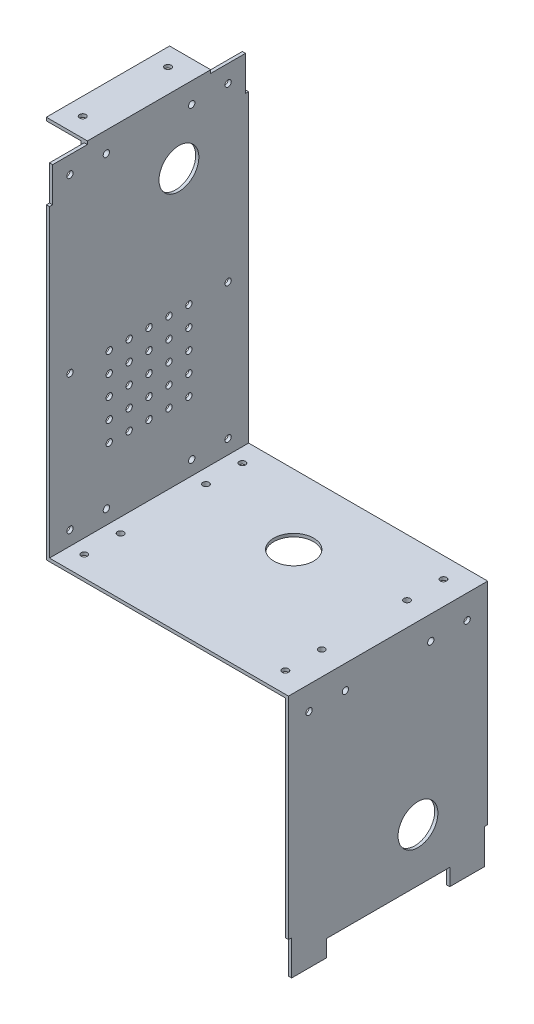
from build123d import *

# Parameters (mm, degrees)
BOSS_EXTRU_1_DEPTH       = 100
ESQUISSE2_W              = 19.05
ESQUISSE2_H              = 61.9
BOSS_EXTRU_2_DEPTH       = 1.5875
ESQUISSE3_W              = 1.5875
ESQUISSE3_H              = 61.9
BOSS_EXTRU_3_DEPTH       = 17.4625
ESQUISSE4_W              = 61.9
ESQUISSE4_H              = 19.05
BOSS_EXTRU_4_DEPTH       = 1.5875
ESQUISSE5_W              = 61.9
ESQUISSE5_H              = 1.5875
BOSS_EXTRU_5_DEPTH       = 17.4625
ESQUISSE7_W              = 61.9
ESQUISSE7_H              = 19.05
BOSS_EXTRU_6_DEPTH       = 1.5875
ESQUISSE8_W              = 61.9
ESQUISSE8_H              = 1.5875
BOSS_EXTRU_7_DEPTH       = 17.4625
ENL_V_MAT_EXTRU_1_REACH  = 125.175
ESQUISSE11_R             = 1.5875
ENL_V_MAT_EXTRU_2_REACH  = 177.005
ESQUISSE12_R             = 1.5875
ENL_V_MAT_EXTRU_3_REACH  = 5.175
ESQUISSE13_R             = 1.5875
ENL_V_MAT_EXTRU_4_REACH  = 3.588
ESQUISSE14_R             = 1.5875
ENL_V_MAT_EXTRU_6_REACH  = 123.588
ESQUISSE16_R             = 10
ENL_V_MAT_EXTRU_7_REACH  = 175.418
ESQUISSE17_R             = 10
ENL_V_MAT_EXTRU_8_REACH  = 123.588
ESQUISSE18_R             = 1.5875
ENL_V_MAT_EXTRU_9_REACH  = 3.588
ESQUISSE19_R             = 1.5875
ENL_V_MAT_EXTRU_10_REACH = 175.418
ESQUISSE20_R             = 1.5875
ESQUISSE21_R             = 1.5875
ENL_V_MAT_EXTRU_11_DEPTH = 1.5875
ENL_V_MAT_EXTRU_12_REACH = 3.588
ESQUISSE22_R             = 10


with BuildPart() as part:
    # Esquisse1 → Boss.-Extru.1 (new body)
    with BuildSketch(Plane.XY):
        Polygon((-113.850503037, 166.83494186), (-113.850503037, -6.58255814), (6.149496963, -6.58255814), (6.149496963, -129.94130814), (7.736996963, -129.94130814), (7.736996963, -4.99505814), (-112.263003037, -4.99505814), (-112.263003037, 166.83494186), align=None)
    extrude(amount=BOSS_EXTRU_1_DEPTH)

    # Esquisse2 → Boss.-Extru.2 (add)
    with BuildSketch(Plane.XZ.offset(6.58255814)):
        with Locations((-105.913003037, 50)):
            Rectangle(ESQUISSE2_W, ESQUISSE2_H)
    extrude(amount=BOSS_EXTRU_2_DEPTH)

    # Esquisse3 → Boss.-Extru.3 (add)
    with BuildSketch(Plane(origin=(0, -6.58255814, 0), x_dir=(1, 0, 0), z_dir=(0, 1, 0))):
        with Locations((-114.644253037, -50)):
            Rectangle(ESQUISSE3_W, ESQUISSE3_H)
    extrude(amount=BOSS_EXTRU_3_DEPTH)

    # Esquisse4 → Boss.-Extru.4 (add)
    with BuildSketch(Plane.ZY.offset(-6.149496963)):
        with Locations((50, -16.10755814)):
            Rectangle(ESQUISSE4_W, ESQUISSE4_H)
    extrude(amount=BOSS_EXTRU_4_DEPTH)

    # Esquisse5 → Boss.-Extru.5 (add)
    with BuildSketch(Plane.ZY.offset(-4.561996963)):
        with Locations((50, -7.37630814)):
            Rectangle(ESQUISSE5_W, ESQUISSE5_H)
    extrude(amount=BOSS_EXTRU_5_DEPTH)

    # Esquisse7 → Boss.-Extru.6 (add)
    with BuildSketch(Plane.ZY.offset(113.850503037)):
        with Locations((50, 157.30994186)):
            Rectangle(ESQUISSE7_W, ESQUISSE7_H)
    extrude(amount=BOSS_EXTRU_6_DEPTH)

    # Esquisse8 → Boss.-Extru.7 (add)
    with BuildSketch(Plane.ZY.offset(115.438003037)):
        with Locations((50, 166.04119186)):
            Rectangle(ESQUISSE8_W, ESQUISSE8_H)
    extrude(amount=BOSS_EXTRU_7_DEPTH)

    # Esquisse11 → Enlèv. mat.-Extru.1 (cut, up to next)
    with BuildSketch(Plane.ZY.offset(115.438003037), mode=Mode.PRIVATE) as enl_v_mat_extru_1_sk1:
        with Locations((71.425, 156.51619186)):
            Circle(ESQUISSE11_R)
    enl_v_mat_extru_1_tool1 = extrude(enl_v_mat_extru_1_sk1.sketch, amount=-ENL_V_MAT_EXTRU_1_REACH, mode=Mode.PRIVATE) & part.part
    add(enl_v_mat_extru_1_tool1.solids().sort_by_distance((-115.438003, 156.516192, 71.425))[0], mode=Mode.SUBTRACT)
    # Esquisse11 → Enlèv. mat.-Extru.1 (cut, up to next)
    with BuildSketch(Plane.ZY.offset(115.438003037), mode=Mode.PRIVATE) as enl_v_mat_extru_1_sk2:
        with Locations((28.575, 156.51619186)):
            Circle(ESQUISSE11_R)
    enl_v_mat_extru_1_tool2 = extrude(enl_v_mat_extru_1_sk2.sketch, amount=-ENL_V_MAT_EXTRU_1_REACH, mode=Mode.PRIVATE) & part.part
    add(enl_v_mat_extru_1_tool2.solids().sort_by_distance((-115.438003, 156.516192, 28.575))[0], mode=Mode.SUBTRACT)
    # Esquisse11 → Enlèv. mat.-Extru.1 (cut, up to next)
    with BuildSketch(Plane.ZY.offset(115.438003037), mode=Mode.PRIVATE) as enl_v_mat_extru_1_sk3:
        with Locations((71.425, 2.14869186)):
            Circle(ESQUISSE11_R)
    enl_v_mat_extru_1_tool3 = extrude(enl_v_mat_extru_1_sk3.sketch, amount=-ENL_V_MAT_EXTRU_1_REACH, mode=Mode.PRIVATE) & part.part
    add(enl_v_mat_extru_1_tool3.solids().sort_by_distance((-115.438003, 2.148692, 71.425))[0], mode=Mode.SUBTRACT)
    # Esquisse11 → Enlèv. mat.-Extru.1 (cut, up to next)
    with BuildSketch(Plane.ZY.offset(115.438003037), mode=Mode.PRIVATE) as enl_v_mat_extru_1_sk4:
        with Locations((28.575, 2.14869186)):
            Circle(ESQUISSE11_R)
    enl_v_mat_extru_1_tool4 = extrude(enl_v_mat_extru_1_sk4.sketch, amount=-ENL_V_MAT_EXTRU_1_REACH, mode=Mode.PRIVATE) & part.part
    add(enl_v_mat_extru_1_tool4.solids().sort_by_distance((-115.438003, 2.148692, 28.575))[0], mode=Mode.SUBTRACT)

    # Esquisse12 → Enlèv. mat.-Extru.2 (cut, up to next)
    with BuildSketch(Plane.XZ.offset(8.17005814), mode=Mode.PRIVATE) as enl_v_mat_extru_2_sk1:
        with Locations((-105.119253037, 71.425)):
            Circle(ESQUISSE12_R)
    enl_v_mat_extru_2_tool1 = extrude(enl_v_mat_extru_2_sk1.sketch, amount=-ENL_V_MAT_EXTRU_2_REACH, mode=Mode.PRIVATE) & part.part
    add(enl_v_mat_extru_2_tool1.solids().sort_by_distance((-105.119253, -8.170058, 71.425))[0], mode=Mode.SUBTRACT)
    # Esquisse12 → Enlèv. mat.-Extru.2 (cut, up to next)
    with BuildSketch(Plane.XZ.offset(8.17005814), mode=Mode.PRIVATE) as enl_v_mat_extru_2_sk2:
        with Locations((-105.119253037, 28.575)):
            Circle(ESQUISSE12_R)
    enl_v_mat_extru_2_tool2 = extrude(enl_v_mat_extru_2_sk2.sketch, amount=-ENL_V_MAT_EXTRU_2_REACH, mode=Mode.PRIVATE) & part.part
    add(enl_v_mat_extru_2_tool2.solids().sort_by_distance((-105.119253, -8.170058, 28.575))[0], mode=Mode.SUBTRACT)
    # Esquisse12 → Enlèv. mat.-Extru.2 (cut, up to next)
    with BuildSketch(Plane.XZ.offset(8.17005814), mode=Mode.PRIVATE) as enl_v_mat_extru_2_sk3:
        with Locations((-4.169253037, 71.425)):
            Circle(ESQUISSE12_R)
    enl_v_mat_extru_2_tool3 = extrude(enl_v_mat_extru_2_sk3.sketch, amount=-ENL_V_MAT_EXTRU_2_REACH, mode=Mode.PRIVATE) & part.part
    add(enl_v_mat_extru_2_tool3.solids().sort_by_distance((-4.169253, -8.170058, 71.425))[0], mode=Mode.SUBTRACT)
    # Esquisse12 → Enlèv. mat.-Extru.2 (cut, up to next)
    with BuildSketch(Plane.XZ.offset(8.17005814), mode=Mode.PRIVATE) as enl_v_mat_extru_2_sk4:
        with Locations((-4.169253037, 28.575)):
            Circle(ESQUISSE12_R)
    enl_v_mat_extru_2_tool4 = extrude(enl_v_mat_extru_2_sk4.sketch, amount=-ENL_V_MAT_EXTRU_2_REACH, mode=Mode.PRIVATE) & part.part
    add(enl_v_mat_extru_2_tool4.solids().sort_by_distance((-4.169253, -8.170058, 28.575))[0], mode=Mode.SUBTRACT)

    # Esquisse13 → Enlèv. mat.-Extru.3 (cut, up to next)
    with BuildSketch(Plane.ZY.offset(-4.561996963), mode=Mode.PRIVATE) as enl_v_mat_extru_3_sk1:
        with Locations((71.425, -16.90130814)):
            Circle(ESQUISSE13_R)
    enl_v_mat_extru_3_tool1 = extrude(enl_v_mat_extru_3_sk1.sketch, amount=-ENL_V_MAT_EXTRU_3_REACH, mode=Mode.PRIVATE) & part.part
    add(enl_v_mat_extru_3_tool1.solids().sort_by_distance((4.561997, -16.901308, 71.425))[0], mode=Mode.SUBTRACT)
    # Esquisse13 → Enlèv. mat.-Extru.3 (cut, up to next)
    with BuildSketch(Plane.ZY.offset(-4.561996963), mode=Mode.PRIVATE) as enl_v_mat_extru_3_sk2:
        with Locations((28.575, -16.90130814)):
            Circle(ESQUISSE13_R)
    enl_v_mat_extru_3_tool2 = extrude(enl_v_mat_extru_3_sk2.sketch, amount=-ENL_V_MAT_EXTRU_3_REACH, mode=Mode.PRIVATE) & part.part
    add(enl_v_mat_extru_3_tool2.solids().sort_by_distance((4.561997, -16.901308, 28.575))[0], mode=Mode.SUBTRACT)

    # Esquisse14 → Enlèv. mat.-Extru.4 (cut, up to next)
    with BuildSketch(Plane.XZ.offset(-165.24744186), mode=Mode.PRIVATE) as enl_v_mat_extru_4_sk1:
        with Locations((-124.169253037, 71.425)):
            Circle(ESQUISSE14_R)
    enl_v_mat_extru_4_tool1 = extrude(enl_v_mat_extru_4_sk1.sketch, amount=-ENL_V_MAT_EXTRU_4_REACH, mode=Mode.PRIVATE) & part.part
    add(enl_v_mat_extru_4_tool1.solids().sort_by_distance((-124.169253, 165.247442, 71.425))[0], mode=Mode.SUBTRACT)
    # Esquisse14 → Enlèv. mat.-Extru.4 (cut, up to next)
    with BuildSketch(Plane.XZ.offset(-165.24744186), mode=Mode.PRIVATE) as enl_v_mat_extru_4_sk2:
        with Locations((-124.169253037, 28.575)):
            Circle(ESQUISSE14_R)
    enl_v_mat_extru_4_tool2 = extrude(enl_v_mat_extru_4_sk2.sketch, amount=-ENL_V_MAT_EXTRU_4_REACH, mode=Mode.PRIVATE) & part.part
    add(enl_v_mat_extru_4_tool2.solids().sort_by_distance((-124.169253, 165.247442, 28.575))[0], mode=Mode.SUBTRACT)

    # Esquisse16 → Enlèv. mat.-Extru.6 (cut, up to next)
    with BuildSketch(Plane.ZY.offset(113.850503037), mode=Mode.PRIVATE) as enl_v_mat_extru_6_sk1:
        with Locations((35, 131.83494186)):
            Circle(ESQUISSE16_R)
    enl_v_mat_extru_6_tool1 = extrude(enl_v_mat_extru_6_sk1.sketch, amount=-ENL_V_MAT_EXTRU_6_REACH, mode=Mode.PRIVATE) & part.part
    add(enl_v_mat_extru_6_tool1.solids().sort_by_distance((-113.850503, 131.834942, 35))[0], mode=Mode.SUBTRACT)

    # Esquisse17 → Enlèv. mat.-Extru.7 (cut, up to next)
    with BuildSketch(Plane.XZ.offset(6.58255814), mode=Mode.PRIVATE) as enl_v_mat_extru_7_sk1:
        with Locations((-54.644253037, 35)):
            Circle(ESQUISSE17_R)
    enl_v_mat_extru_7_tool1 = extrude(enl_v_mat_extru_7_sk1.sketch, amount=-ENL_V_MAT_EXTRU_7_REACH, mode=Mode.PRIVATE) & part.part
    add(enl_v_mat_extru_7_tool1.solids().sort_by_distance((-54.644253, -6.582558, 35))[0], mode=Mode.SUBTRACT)

    # Esquisse18 → Enlèv. mat.-Extru.8 (cut, up to next)
    with BuildSketch(Plane.ZY.offset(113.850503037), mode=Mode.PRIVATE) as enl_v_mat_extru_8_sk1:
        with Locations((10.31875, 156.51619186)):
            Circle(ESQUISSE18_R)
    enl_v_mat_extru_8_tool1 = extrude(enl_v_mat_extru_8_sk1.sketch, amount=-ENL_V_MAT_EXTRU_8_REACH, mode=Mode.PRIVATE) & part.part
    add(enl_v_mat_extru_8_tool1.solids().sort_by_distance((-113.850503, 156.516192, 10.31875))[0], mode=Mode.SUBTRACT)
    # Esquisse18 → Enlèv. mat.-Extru.8 (cut, up to next)
    with BuildSketch(Plane.ZY.offset(113.850503037), mode=Mode.PRIVATE) as enl_v_mat_extru_8_sk2:
        with Locations((10.31875, 2.14869186)):
            Circle(ESQUISSE18_R)
    enl_v_mat_extru_8_tool2 = extrude(enl_v_mat_extru_8_sk2.sketch, amount=-ENL_V_MAT_EXTRU_8_REACH, mode=Mode.PRIVATE) & part.part
    add(enl_v_mat_extru_8_tool2.solids().sort_by_distance((-113.850503, 2.148692, 10.31875))[0], mode=Mode.SUBTRACT)
    # Esquisse18 → Enlèv. mat.-Extru.8 (cut, up to next)
    with BuildSketch(Plane.ZY.offset(113.850503037), mode=Mode.PRIVATE) as enl_v_mat_extru_8_sk3:
        with Locations((10.31875, 70.19869186)):
            Circle(ESQUISSE18_R)
    enl_v_mat_extru_8_tool3 = extrude(enl_v_mat_extru_8_sk3.sketch, amount=-ENL_V_MAT_EXTRU_8_REACH, mode=Mode.PRIVATE) & part.part
    add(enl_v_mat_extru_8_tool3.solids().sort_by_distance((-113.850503, 70.198692, 10.31875))[0], mode=Mode.SUBTRACT)
    # Esquisse18 → Enlèv. mat.-Extru.8 (cut, up to next)
    with BuildSketch(Plane.ZY.offset(113.850503037), mode=Mode.PRIVATE) as enl_v_mat_extru_8_sk4:
        with Locations((89.68125, 2.14869186)):
            Circle(ESQUISSE18_R)
    enl_v_mat_extru_8_tool4 = extrude(enl_v_mat_extru_8_sk4.sketch, amount=-ENL_V_MAT_EXTRU_8_REACH, mode=Mode.PRIVATE) & part.part
    add(enl_v_mat_extru_8_tool4.solids().sort_by_distance((-113.850503, 2.148692, 89.68125))[0], mode=Mode.SUBTRACT)
    # Esquisse18 → Enlèv. mat.-Extru.8 (cut, up to next)
    with BuildSketch(Plane.ZY.offset(113.850503037), mode=Mode.PRIVATE) as enl_v_mat_extru_8_sk5:
        with Locations((89.68125, 70.19869186)):
            Circle(ESQUISSE18_R)
    enl_v_mat_extru_8_tool5 = extrude(enl_v_mat_extru_8_sk5.sketch, amount=-ENL_V_MAT_EXTRU_8_REACH, mode=Mode.PRIVATE) & part.part
    add(enl_v_mat_extru_8_tool5.solids().sort_by_distance((-113.850503, 70.198692, 89.68125))[0], mode=Mode.SUBTRACT)
    # Esquisse18 → Enlèv. mat.-Extru.8 (cut, up to next)
    with BuildSketch(Plane.ZY.offset(113.850503037), mode=Mode.PRIVATE) as enl_v_mat_extru_8_sk6:
        with Locations((89.68125, 156.51619186)):
            Circle(ESQUISSE18_R)
    enl_v_mat_extru_8_tool6 = extrude(enl_v_mat_extru_8_sk6.sketch, amount=-ENL_V_MAT_EXTRU_8_REACH, mode=Mode.PRIVATE) & part.part
    add(enl_v_mat_extru_8_tool6.solids().sort_by_distance((-113.850503, 156.516192, 89.68125))[0], mode=Mode.SUBTRACT)
    # Esquisse18 → Enlèv. mat.-Extru.8 (cut, up to next)
    with BuildSketch(Plane.ZY.offset(113.850503037), mode=Mode.PRIVATE) as enl_v_mat_extru_8_sk7:
        Polygon((0, 166.83494186), (1.5875, 166.83494186), (19.05, 166.83494186), (19.05, 165.24744186), (1.5875, 165.24744186), (1.5875, 147.78494186), (0, 147.78494186), align=None)
    enl_v_mat_extru_8_tool7 = extrude(enl_v_mat_extru_8_sk7.sketch, amount=-ENL_V_MAT_EXTRU_8_REACH, mode=Mode.PRIVATE) & part.part
    add(enl_v_mat_extru_8_tool7.solids().sort_by_distance((-113.850503, 166.565534, 0.79375))[0], mode=Mode.SUBTRACT)
    # Esquisse18 → Enlèv. mat.-Extru.8 (cut, up to next)
    with BuildSketch(Plane.ZY.offset(113.850503037), mode=Mode.PRIVATE) as enl_v_mat_extru_8_sk8:
        Polygon((98.4125, 165.24744186), (98.4125, 147.78494186), (100, 147.78494186), (100, 166.83494186), (98.4125, 166.83494186), (80.95, 166.83494186), (80.95, 165.24744186), align=None)
    enl_v_mat_extru_8_tool8 = extrude(enl_v_mat_extru_8_sk8.sketch, amount=-ENL_V_MAT_EXTRU_8_REACH, mode=Mode.PRIVATE) & part.part
    add(enl_v_mat_extru_8_tool8.solids().sort_by_distance((-113.850503, 156.516192, 98.681908))[0], mode=Mode.SUBTRACT)

    # Esquisse19 → Enlèv. mat.-Extru.9 (cut, up to next)
    with BuildSketch(Plane.ZY.offset(-6.149496963), mode=Mode.PRIVATE) as enl_v_mat_extru_9_sk1:
        with Locations((10.31875, -16.90130814)):
            Circle(ESQUISSE19_R)
    enl_v_mat_extru_9_tool1 = extrude(enl_v_mat_extru_9_sk1.sketch, amount=-ENL_V_MAT_EXTRU_9_REACH, mode=Mode.PRIVATE) & part.part
    add(enl_v_mat_extru_9_tool1.solids().sort_by_distance((6.149497, -16.901308, 10.31875))[0], mode=Mode.SUBTRACT)
    # Esquisse19 → Enlèv. mat.-Extru.9 (cut, up to next)
    with BuildSketch(Plane.ZY.offset(-6.149496963), mode=Mode.PRIVATE) as enl_v_mat_extru_9_sk2:
        with Locations((89.68125, -16.90130814)):
            Circle(ESQUISSE19_R)
    enl_v_mat_extru_9_tool2 = extrude(enl_v_mat_extru_9_sk2.sketch, amount=-ENL_V_MAT_EXTRU_9_REACH, mode=Mode.PRIVATE) & part.part
    add(enl_v_mat_extru_9_tool2.solids().sort_by_distance((6.149497, -16.901308, 89.68125))[0], mode=Mode.SUBTRACT)

    # Esquisse20 → Enlèv. mat.-Extru.10 (cut, up to next)
    with BuildSketch(Plane.XZ.offset(6.58255814), mode=Mode.PRIVATE) as enl_v_mat_extru_10_sk1:
        with Locations((-105.119253037, 10.31875)):
            Circle(ESQUISSE20_R)
    enl_v_mat_extru_10_tool1 = extrude(enl_v_mat_extru_10_sk1.sketch, amount=-ENL_V_MAT_EXTRU_10_REACH, mode=Mode.PRIVATE) & part.part
    add(enl_v_mat_extru_10_tool1.solids().sort_by_distance((-105.119253, -6.582558, 10.31875))[0], mode=Mode.SUBTRACT)
    # Esquisse20 → Enlèv. mat.-Extru.10 (cut, up to next)
    with BuildSketch(Plane.XZ.offset(6.58255814), mode=Mode.PRIVATE) as enl_v_mat_extru_10_sk2:
        with Locations((-4.169253037, 10.31875)):
            Circle(ESQUISSE20_R)
    enl_v_mat_extru_10_tool2 = extrude(enl_v_mat_extru_10_sk2.sketch, amount=-ENL_V_MAT_EXTRU_10_REACH, mode=Mode.PRIVATE) & part.part
    add(enl_v_mat_extru_10_tool2.solids().sort_by_distance((-4.169253, -6.582558, 10.31875))[0], mode=Mode.SUBTRACT)
    # Esquisse20 → Enlèv. mat.-Extru.10 (cut, up to next)
    with BuildSketch(Plane.XZ.offset(6.58255814), mode=Mode.PRIVATE) as enl_v_mat_extru_10_sk3:
        with Locations((-4.169253037, 89.68125)):
            Circle(ESQUISSE20_R)
    enl_v_mat_extru_10_tool3 = extrude(enl_v_mat_extru_10_sk3.sketch, amount=-ENL_V_MAT_EXTRU_10_REACH, mode=Mode.PRIVATE) & part.part
    add(enl_v_mat_extru_10_tool3.solids().sort_by_distance((-4.169253, -6.582558, 89.68125))[0], mode=Mode.SUBTRACT)
    # Esquisse20 → Enlèv. mat.-Extru.10 (cut, up to next)
    with BuildSketch(Plane.XZ.offset(6.58255814), mode=Mode.PRIVATE) as enl_v_mat_extru_10_sk4:
        with Locations((-105.119253037, 89.68125)):
            Circle(ESQUISSE20_R)
    enl_v_mat_extru_10_tool4 = extrude(enl_v_mat_extru_10_sk4.sketch, amount=-ENL_V_MAT_EXTRU_10_REACH, mode=Mode.PRIVATE) & part.part
    add(enl_v_mat_extru_10_tool4.solids().sort_by_distance((-105.119253, -6.582558, 89.68125))[0], mode=Mode.SUBTRACT)

    # Esquisse21 → Enlèv. mat.-Extru.11 (cut)
    with BuildSketch(Plane.ZY.offset(113.850503037)):
        with Locations((30, 70.19869186)):
            Circle(ESQUISSE21_R)
        with Locations((40, 70.19869186)):
            Circle(ESQUISSE21_R)
        with Locations((50, 70.19869186)):
            Circle(ESQUISSE21_R)
        with Locations((60, 70.19869186)):
            Circle(ESQUISSE21_R)
        with Locations((70, 70.19869186)):
            Circle(ESQUISSE21_R)
        with Locations((40, 60.19869186)):
            Circle(ESQUISSE21_R)
        with Locations((50, 60.19869186)):
            Circle(ESQUISSE21_R)
        with Locations((60, 60.19869186)):
            Circle(ESQUISSE21_R)
        with Locations((70, 60.19869186)):
            Circle(ESQUISSE21_R)
        with Locations((40, 50.19869186)):
            Circle(ESQUISSE21_R)
        with Locations((50, 50.19869186)):
            Circle(ESQUISSE21_R)
        with Locations((60, 50.19869186)):
            Circle(ESQUISSE21_R)
        with Locations((70, 50.19869186)):
            Circle(ESQUISSE21_R)
        with Locations((40, 40.19869186)):
            Circle(ESQUISSE21_R)
        with Locations((50, 40.19869186)):
            Circle(ESQUISSE21_R)
        with Locations((60, 40.19869186)):
            Circle(ESQUISSE21_R)
        with Locations((70, 40.19869186)):
            Circle(ESQUISSE21_R)
        with Locations((40, 30.19869186)):
            Circle(ESQUISSE21_R)
        with Locations((50, 30.19869186)):
            Circle(ESQUISSE21_R)
        with Locations((60, 30.19869186)):
            Circle(ESQUISSE21_R)
        with Locations((70, 30.19869186)):
            Circle(ESQUISSE21_R)
        with Locations((30, 60.19869186)):
            Circle(ESQUISSE21_R)
        with Locations((30, 50.19869186)):
            Circle(ESQUISSE21_R)
        with Locations((30, 40.19869186)):
            Circle(ESQUISSE21_R)
        with Locations((30, 30.19869186)):
            Circle(ESQUISSE21_R)
    extrude(amount=-ENL_V_MAT_EXTRU_11_DEPTH, mode=Mode.SUBTRACT)

    # Esquisse22 → Enlèv. mat.-Extru.12 (cut, up to next)
    with BuildSketch(Plane.ZY.offset(-6.149496963), mode=Mode.PRIVATE) as enl_v_mat_extru_12_sk1:
        with Locations((35, -93.35380814)):
            Circle(ESQUISSE22_R)
    enl_v_mat_extru_12_tool1 = extrude(enl_v_mat_extru_12_sk1.sketch, amount=-ENL_V_MAT_EXTRU_12_REACH, mode=Mode.PRIVATE) & part.part
    add(enl_v_mat_extru_12_tool1.solids().sort_by_distance((6.149497, -93.353808, 35))[0], mode=Mode.SUBTRACT)
    # Esquisse22 → Enlèv. mat.-Extru.12 (cut, up to next)
    with BuildSketch(Plane.ZY.offset(-6.149496963), mode=Mode.PRIVATE) as enl_v_mat_extru_12_sk2:
        Polygon((0, -129.94130814), (0, -110.89130814), (1.5875, -110.89130814), (1.5875, -128.35380814), (19.05, -128.35380814), (19.05, -119.94130814), (80.95, -119.94130814), (80.95, -128.35380814), (98.4125, -128.35380814), (98.4125, -110.89130814), (100, -110.89130814), (100, -129.94130814), (19.05, -129.94130814), align=None)
    enl_v_mat_extru_12_tool2 = extrude(enl_v_mat_extru_12_sk2.sketch, amount=-ENL_V_MAT_EXTRU_12_REACH, mode=Mode.PRIVATE) & part.part
    add(enl_v_mat_extru_12_tool2.solids().sort_by_distance((6.149497, -124.886228, 50))[0], mode=Mode.SUBTRACT)


solid = part.part
